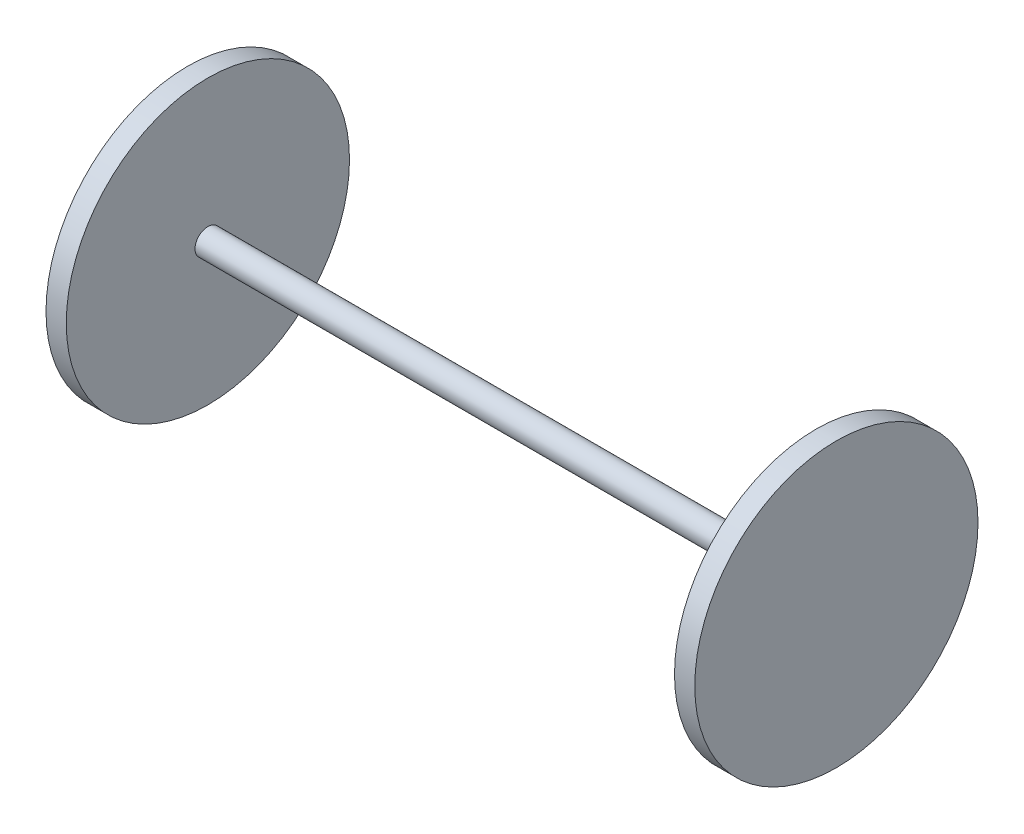
from build123d import *

# Parameters (mm, degrees)
SKETCH1_R           = 3.175
BOSS_EXTRUDE1_DEPTH = 75
SKETCH2_R           = 34.925
BOSS_EXTRUDE2_DEPTH = 5


with BuildPart() as part:
    # Sketch1 → Boss-Extrude1 (new body, symmetric)
    with BuildSketch(Plane(origin=(0, 0, 0), x_dir=(0, 0, -1), z_dir=(1, 0, 0))):
        Circle(SKETCH1_R)
    extrude(amount=BOSS_EXTRUDE1_DEPTH, both=True)

    # Sketch2 → Boss-Extrude2 (add)
    with BuildSketch(Plane(origin=(75, 0, 0), x_dir=(0, 0, -1), z_dir=(1, 0, 0))):
        Circle(SKETCH2_R)
    boss_extrude2 = extrude(amount=BOSS_EXTRUDE2_DEPTH)

    # Mirror1: Boss-Extrude2 across plane
    add(boss_extrude2.mirror(Plane(origin=(0, 0, 0), x_dir=(0, 0, 1), z_dir=(1, 0, 0))))


solid = part.part
